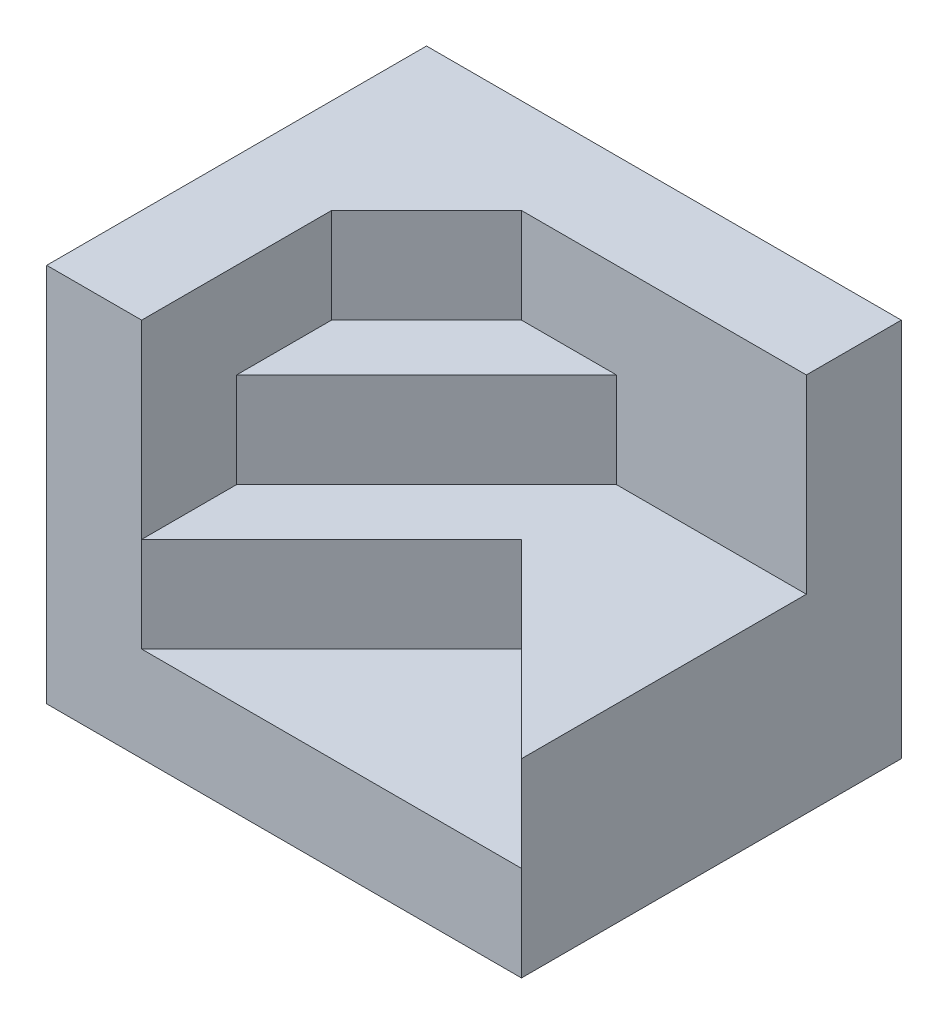
from build123d import *

# Parameters (mm, degrees)
EXTRUDE_2_DEPTH = 20
EXTRUDE_3_DEPTH = 15
EXTRUDE_4_DEPTH = 10
EXTRUDE_5_DEPTH = 5


with BuildPart() as part:
    # 草圖1 → 填料-伸長2 (new body)
    with BuildSketch(Plane(origin=(0, 0, 0), x_dir=(1, 0, 0), z_dir=(0, 1, 0))):
        Polygon((-12.5, -10), (-7.5, -10), (-7.5, 0), (-2.5, 5), (12.5, 5), (12.5, 10), (-12.5, 10), align=None)
    extrude(amount=EXTRUDE_2_DEPTH)

    # 草圖1<4> → 填料-伸長3 (add)
    with BuildSketch(Plane(origin=(0, 0, 0), x_dir=(1, 0, 0), z_dir=(0, 1, 0))):
        Polygon((-7.5, 0), (-7.5, -5), (2.5, 5), (-2.5, 5), align=None)
    extrude(amount=EXTRUDE_3_DEPTH)

    # 草圖1<5> → 填料-伸長4 (add)
    with BuildSketch(Plane(origin=(0, 0, 0), x_dir=(1, 0, 0), z_dir=(0, 1, 0))):
        Polygon((-7.5, -5), (-7.5, -10), (2.5, 0), (12.5, -10), (12.5, 5), (2.5, 5), align=None)
    extrude(amount=EXTRUDE_4_DEPTH)

    # 草圖1<6> → 填料-伸長5 (add)
    with BuildSketch(Plane(origin=(0, 0, 0), x_dir=(1, 0, 0), z_dir=(0, 1, 0))):
        Polygon((2.5, 0), (-7.5, -10), (12.5, -10), align=None)
    extrude(amount=EXTRUDE_5_DEPTH)


solid = part.part
